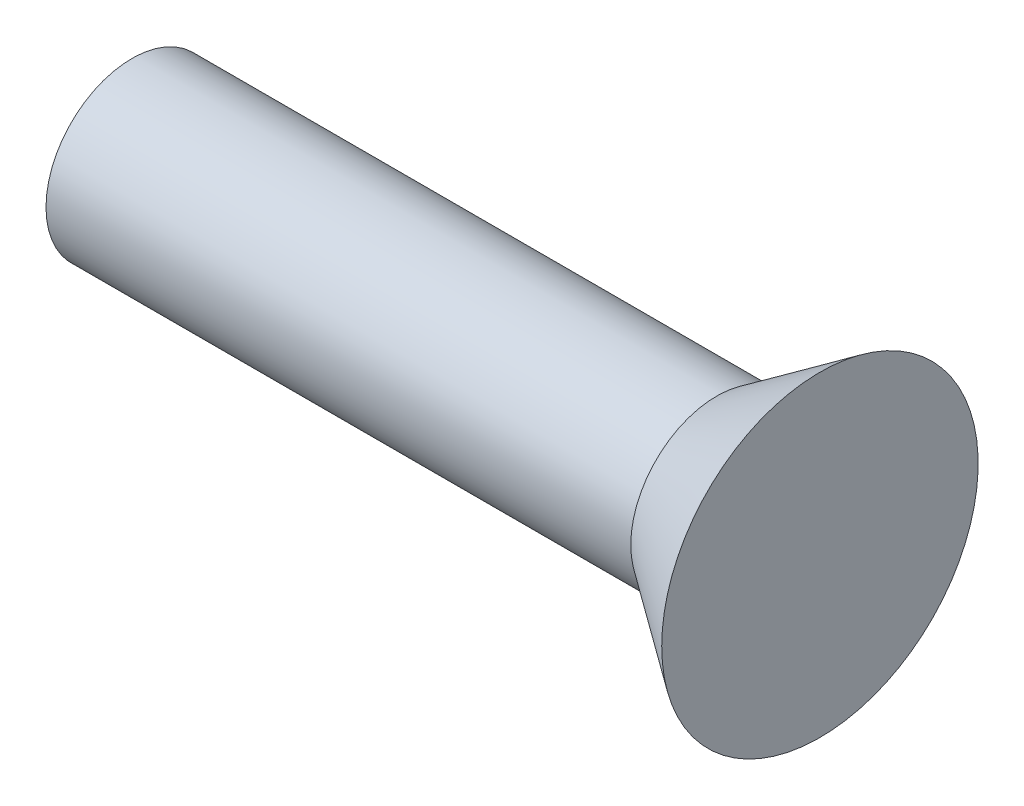
from build123d import *


with BuildPart() as part:
    # 草图1 → 旋转1 (revolve)
    with BuildSketch(Plane.XY):
        Polygon((0, 0), (0, 1.25), (8.5, 1.25), (10, 2.3), (10, 0), align=None)
    revolve(axis=Axis((-53.844089168, 0, 0), (1, 0, 0)))


solid = part.part
